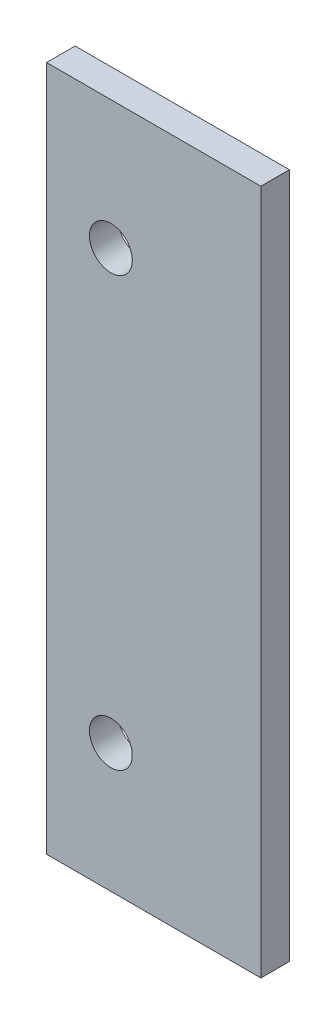
from build123d import *

# Parameters (mm, degrees)
ESQUISSE1_W      = 15
ESQUISSE1_H      = 48
ESQUISSE1_R      = 1.5
EXTRUSION1_DEPTH = 2


with BuildPart() as part:
    # Esquisse1 → Extrusion1 (new body)
    with BuildSketch(Plane.XY):
        with Locations((7.5, -24)):
            Rectangle(ESQUISSE1_W, ESQUISSE1_H)
        with Locations((4.5, -9)):
            Circle(ESQUISSE1_R, mode=Mode.SUBTRACT)
        with Locations((4.5, -39)):
            Circle(ESQUISSE1_R, mode=Mode.SUBTRACT)
    extrude(amount=EXTRUSION1_DEPTH)


solid = part.part
